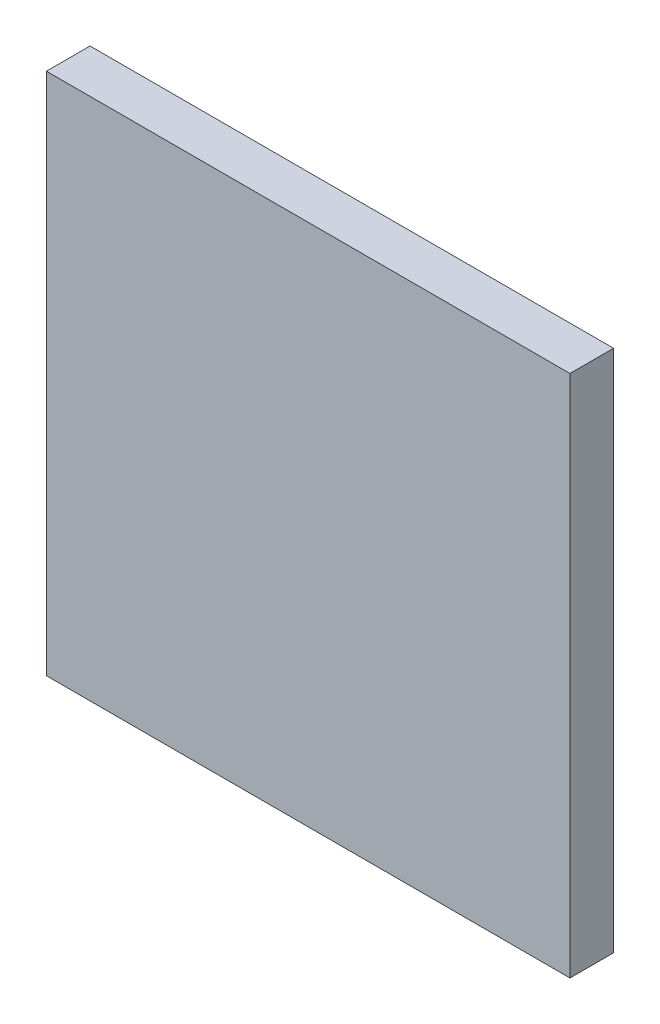
from build123d import *

# Parameters (mm, degrees)
SKETCH1_W           = 76.2
SKETCH1_H           = 76.2
BOSS_EXTRUDE1_DEPTH = 6.35


with BuildPart() as part:
    # Sketch1 → Boss-Extrude1 (new body)
    with BuildSketch(Plane.XY):
        Rectangle(SKETCH1_W, SKETCH1_H)
    extrude(amount=BOSS_EXTRUDE1_DEPTH)


solid = part.part
